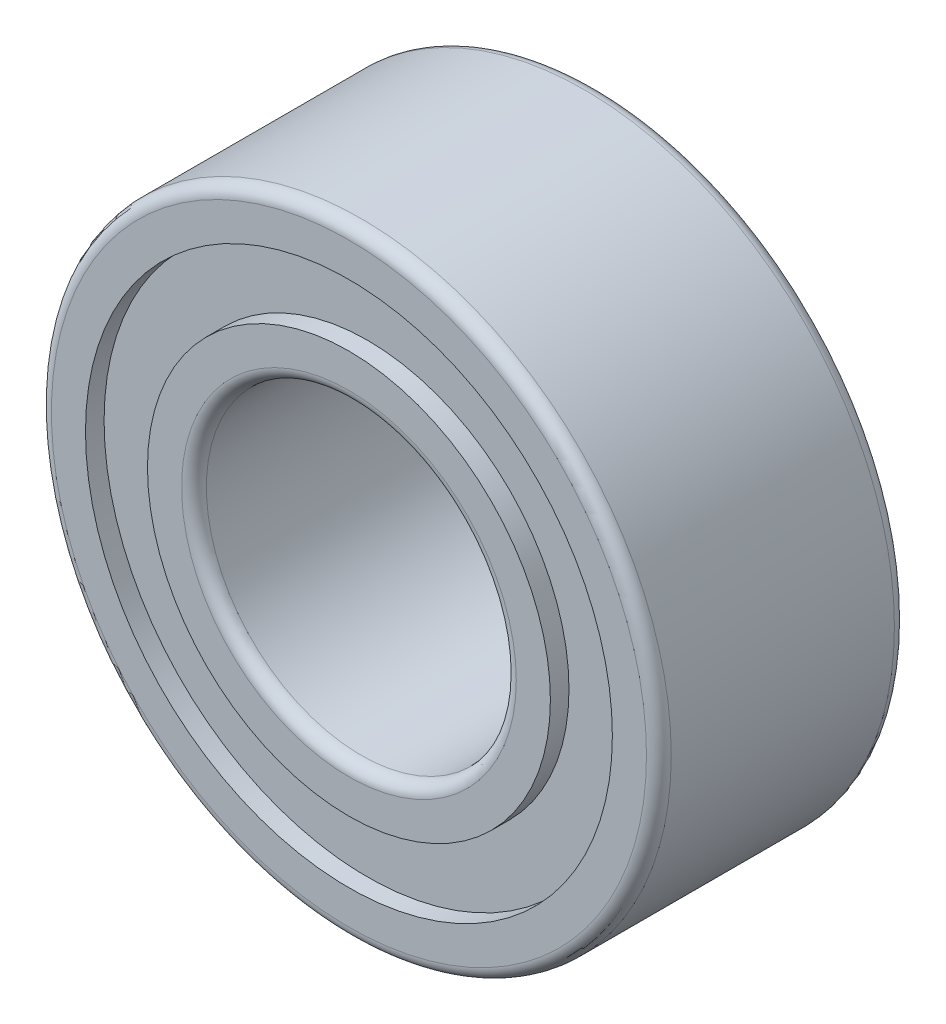
from build123d import *

# Parameters (mm, degrees)
SKETCH_1_R          = 5
SKETCH_1_R_2        = 2.5
EXTRUDE_1_DEPTH     = 4
SKETCH_4_R          = 4.25
SKETCH_4_R_2        = 3.25
CUT_EXTRUDE_3_DEPTH = 0.3
SKETCH_5_R          = 4.25
SKETCH_5_R_2        = 3.25
CUT_EXTRUDE_4_DEPTH = 0.3
FILLET_2_R          = 0.2


with BuildPart() as part:
    # Эскиз1 → Бобышка-Вытянуть1 (new body)
    with BuildSketch(Plane.XY):
        Circle(SKETCH_1_R)
        Circle(SKETCH_1_R_2, mode=Mode.SUBTRACT)
    extrude(amount=EXTRUDE_1_DEPTH)

    # Эскиз4 → Вырез-Вытянуть3 (cut)
    with BuildSketch(Plane.XY.offset(4)):
        Circle(SKETCH_4_R)
        Circle(SKETCH_4_R_2, mode=Mode.SUBTRACT)
    extrude(amount=-CUT_EXTRUDE_3_DEPTH, mode=Mode.SUBTRACT)

    # Эскиз5 → Вырез-Вытянуть4 (cut)
    with BuildSketch(Plane(origin=(0, 0, 0), x_dir=(-1, 0, 0), z_dir=(0, 0, -1))):
        Circle(SKETCH_5_R)
        Circle(SKETCH_5_R_2, mode=Mode.SUBTRACT)
    extrude(amount=-CUT_EXTRUDE_4_DEPTH, mode=Mode.SUBTRACT)

    # Скругление2
    fillet_2_edges = [part.edges().sort_by_distance(p)[0] for p in [
        (-5, 0, 4),
        (-5, 0, 0),
        (-2.5, 0, 0),
        (-2.5, 0, 4),
    ]]
    fillet(fillet_2_edges, radius=FILLET_2_R)


solid = part.part
